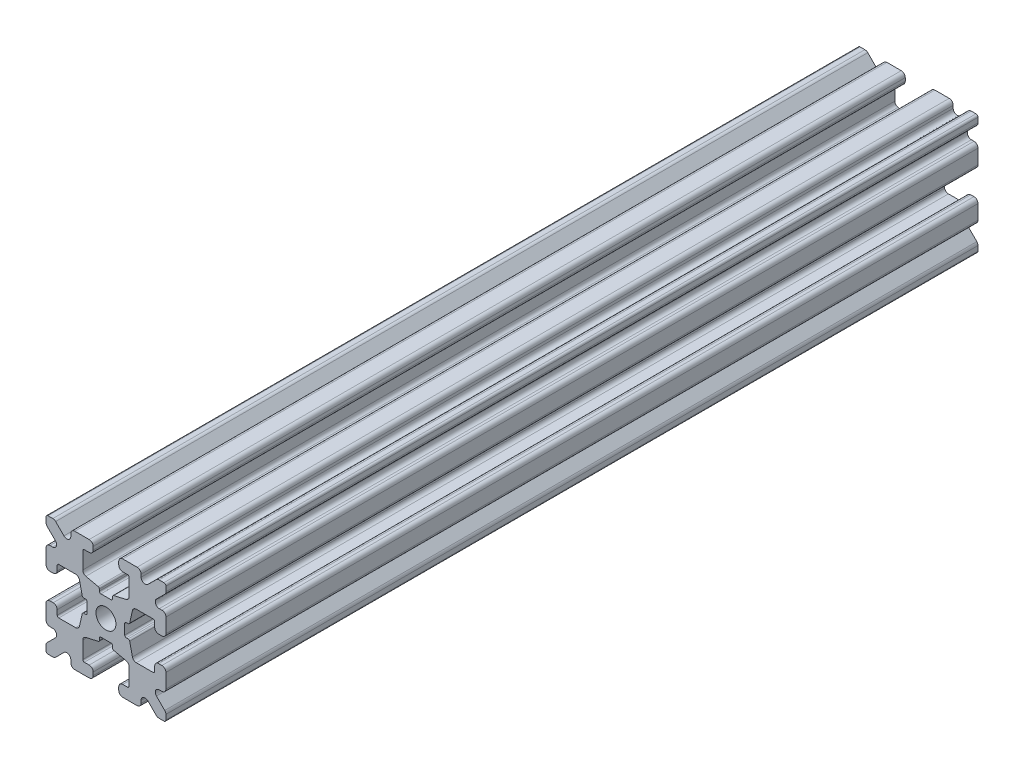
from build123d import *

# Parameters (mm, degrees)
SKETCH1_W           = 15
SKETCH1_H           = 15
SKETCH1_R           = 1.25
BOSS_EXTRUDE1_DEPTH = 50.8
FILLET1_R           = 0.25
CUT_EXTRUDE1_DEPTH  = 102.6
CUT_EXTRUDE3_DEPTH  = 102.6
FILLET3_R           = 0.5
FILLET4_R           = 0.5
FILLET5_R           = 3
FILLET6_R           = 0.2
CUT_EXTRUDE4_DEPTH  = 102.6
FILLET8_R           = 0.5
SKETCH6_W           = 5.1529354
SKETCH6_H           = 1.651
SKETCH6_W_2         = 1.651
SKETCH6_H_2         = 5.1529354
CUT_EXTRUDE5_DEPTH  = 102.6
FILLET10_R          = 0.2


with BuildPart() as part:
    # Sketch1 → Boss-Extrude1 (new body, symmetric)
    with BuildSketch(Plane.XY):
        Rectangle(SKETCH1_W, SKETCH1_H)
        Circle(SKETCH1_R, mode=Mode.SUBTRACT)
    extrude(amount=BOSS_EXTRUDE1_DEPTH, both=True)

    # Fillet1
    fillet1_edges = [part.edges().sort_by_distance(p)[0] for p in [
        (7.5, -7.5, 0),
        (-7.5, -7.5, 0),
        (-7.5, 7.5, 0),
        (7.5, 7.5, 0),
    ]]
    fillet(fillet1_edges, radius=FILLET1_R)

    # Sketch2 → Cut-Extrude1 (cut, through all)
    with BuildSketch(Plane.XY.offset(50.8)):
        Polygon((-7.5, 1.6), (-6.1, 1.6), (-6.1, 2.9), (-3.4, 2.9), (-3.4, -2.9), (-6.1, -2.9), (-6.1, -1.6), (-7.5, -1.6), align=None)
        Polygon((2.9, 6.1), (1.6, 6.1), (1.6, 7.5), (-1.6, 7.5), (-1.6, 6.1), (-2.9, 6.1), (-2.9, 3.4), (2.9, 3.4), align=None)
        Polygon((-1.6, -7.5), (-1.6, -6.1), (-2.9, -6.1), (-2.9, -3.4), (2.9, -3.4), (2.9, -6.1), (1.6, -6.1), (1.6, -7.5), align=None)
        Polygon((6.1, -2.9), (6.1, -1.6), (7.5, -1.6), (7.5, 1.6), (6.1, 1.6), (6.1, 2.9), (3.4, 2.9), (3.4, -2.9), align=None)
    extrude(amount=-CUT_EXTRUDE1_DEPTH, mode=Mode.SUBTRACT)

    # Sketch4 → Cut-Extrude3 (cut, through all)
    with BuildSketch(Plane.XY.offset(50.8)):
        Polygon((-3.4, 2.9), (-2.75, 0), (-3.4, -2.9), align=None)
        Polygon((-2.9, 3.4), (0, 2.75), (2.9, 3.4), align=None)
        Polygon((3.4, 2.9), (2.75, 0), (3.4, -2.9), align=None)
        Polygon((-2.9, -3.4), (0, -2.75), (2.9, -3.4), align=None)
    extrude(amount=-CUT_EXTRUDE3_DEPTH, mode=Mode.SUBTRACT)

    # Fillet3
    fillet3_edges = [part.edges().sort_by_distance(p)[0] for p in [
        (1.6, -7.5, 0),
        (-1.6, -7.5, 0),
        (-1.6, -6.1, 0),
        (1.6, -6.1, 0),
        (6.1, 1.6, 0),
        (7.5, 1.6, 0),
        (7.5, -1.6, 0),
        (6.1, -1.6, 0),
        (-7.5, -1.6, 0),
        (-7.5, 1.6, 0),
        (-6.1, 1.6, 0),
        (-6.1, -1.6, 0),
        (-1.6, 6.1, 0),
        (-1.6, 7.5, 0),
        (1.6, 7.5, 0),
        (1.6, 6.1, 0),
    ]]
    fillet(fillet3_edges, radius=FILLET3_R)

    # Fillet4
    fillet4_edges = [part.edges().sort_by_distance(p)[0] for p in [
        (-2.9, -3.4, 0),
        (2.9, -3.4, 0),
        (3.4, -2.9, 0),
        (3.4, 2.9, 0),
        (-3.4, 2.9, 0),
        (-3.4, -2.9, 0),
        (2.9, 3.4, 0),
        (-2.9, 3.4, 0),
    ]]
    fillet(fillet4_edges, radius=FILLET4_R)

    # Fillet5
    fillet5_edges = [part.edges().sort_by_distance(p)[0] for p in [
        (-2.75, 0, 0),
        (0, 2.75, 0),
        (2.75, 0, 0),
        (0, -2.75, 0),
    ]]
    fillet(fillet5_edges, radius=FILLET5_R)

    # Fillet6
    fillet6_edges = [part.edges().sort_by_distance(p)[0] for p in [
        (-2.9, -6.1, 0),
        (2.9, -6.1, 0),
        (6.1, -2.9, 0),
        (6.1, 2.9, 0),
        (-6.1, 2.9, 0),
        (-6.1, -2.9, 0),
        (2.9, 6.1, 0),
        (-2.9, 6.1, 0),
    ]]
    fillet(fillet6_edges, radius=FILLET6_R)

    # Sketch5 → Cut-Extrude4 (cut, through all)
    with BuildSketch(Plane.XY.offset(50.8)):
        Polygon((-7.5, 6.439339828), (-5.460660172, 4.4), (-7.5, 4.4), align=None)
        Polygon((-6.439339828, 7.5), (-4.4, 5.460660172), (-4.4, 7.5), align=None)
        Polygon((4.4, 7.5), (6.439339828, 7.5), (4.4, 5.460660172), align=None)
        Polygon((7.5, 6.439339828), (7.5, 4.4), (5.460660172, 4.4), align=None)
        Polygon((7.5, -6.439339828), (5.460660172, -4.4), (7.5, -4.4), align=None)
        Polygon((6.439339828, -7.5), (4.4, -5.460660172), (4.4, -7.5), align=None)
        Polygon((-4.4, -7.5), (-6.439339828, -7.5), (-4.4, -5.460660172), align=None)
        Polygon((-7.5, -6.439339828), (-7.5, -4.4), (-5.460660172, -4.4), align=None)
    extrude(amount=-CUT_EXTRUDE4_DEPTH, mode=Mode.SUBTRACT)

    # Fillet8
    fillet8_edges = [part.edges().sort_by_distance(p)[0] for p in [
        (-7.5, 4.4, 0),
        (-7.5, 6.439339828, 0),
        (-5.460660172, 4.4, 0),
        (7.5, -4.4, 0),
        (7.5, -6.439339828, 0),
        (5.460660172, -4.4, 0),
        (5.460660172, 4.4, 0),
        (7.5, 6.439339828, 0),
        (7.5, 4.4, 0),
        (-4.4, 7.5, 0),
        (-4.4, 5.460660172, 0),
        (-6.439339828, 7.5, 0),
        (-5.460660172, -4.4, 0),
        (-7.5, -6.439339828, 0),
        (-7.5, -4.4, 0),
        (4.4, 5.460660172, 0),
        (4.4, 7.5, 0),
        (6.439339828, 7.5, 0),
        (6.439339828, -7.5, 0),
        (4.4, -7.5, 0),
        (4.4, -5.460660172, 0),
        (-6.439339828, -7.5, 0),
        (-4.4, -5.460660172, 0),
        (-4.4, -7.5, 0),
    ]]
    fillet(fillet8_edges, radius=FILLET8_R)

    # Sketch6 → Cut-Extrude5 (cut, through all)
    with BuildSketch(Plane.XY.offset(50.8)):
        with Locations((4.9235323, 0)):
            Rectangle(SKETCH6_W, SKETCH6_H)
        with Locations((0, -4.9235323)):
            Rectangle(SKETCH6_W_2, SKETCH6_H_2)
        with Locations((-4.9235323, 0)):
            Rectangle(SKETCH6_W, SKETCH6_H)
        with Locations((0, 4.9235323)):
            Rectangle(SKETCH6_W_2, SKETCH6_H_2)
    extrude(amount=-CUT_EXTRUDE5_DEPTH, mode=Mode.SUBTRACT)

    # Fillet10
    fillet10_edges = [part.edges().sort_by_distance(p)[0] for p in [
        (0.8255, -2.935025862, 0),
        (-0.8255, -2.935025862, 0),
        (0.8255, -2.3470646, 0),
        (-0.8255, -2.3470646, 0),
        (2.935025862, 0.8255, 0),
        (2.935025862, -0.8255, 0),
        (2.3470646, 0.8255, 0),
        (2.3470646, -0.8255, 0),
        (-2.935025862, -0.8255, 0),
        (-2.935025862, 0.8255, 0),
        (-2.3470646, -0.8255, 0),
        (-2.3470646, 0.8255, 0),
        (-0.8255, 2.935025862, 0),
        (0.8255, 2.935025862, 0),
        (-0.8255, 2.3470646, 0),
        (0.8255, 2.3470646, 0),
    ]]
    fillet(fillet10_edges, radius=FILLET10_R)


solid = part.part
